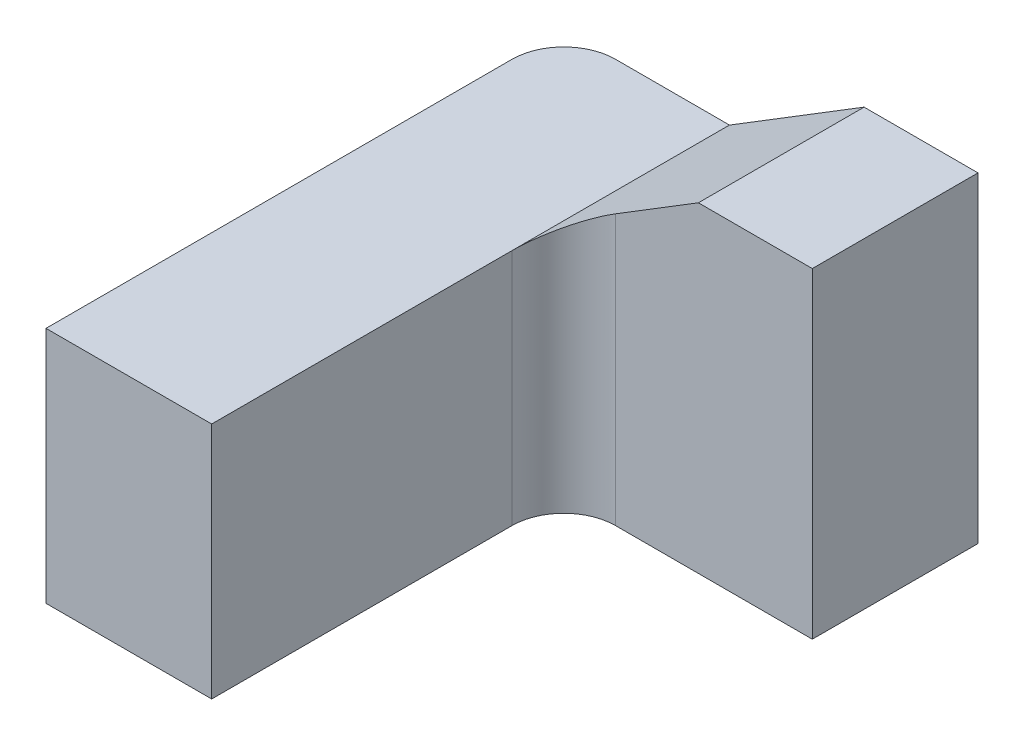
from build123d import *

# Parameters (mm, degrees)
EXTRUDE_1_DEPTH = 0.16
SKETCH_2_W      = 0.16
SKETCH_2_H      = 0.23
EXTRUDE_2_DEPTH = 0.34
FILLET_1_R      = 0.05


with BuildPart() as part:
    # 草图1 → 凸台-拉伸1 (new body)
    with BuildSketch(Plane.XY):
        Polygon((0, 0), (0, 0.23), (0.16, 0.23), (0.29, 0.31), (0.4, 0.31), (0.4, 0), align=None)
    extrude(amount=EXTRUDE_1_DEPTH)

    # 草图2 → 凸台-拉伸2 (add)
    with BuildSketch(Plane.XY.offset(0.16)):
        with Locations((0.08, 0.115)):
            Rectangle(SKETCH_2_W, SKETCH_2_H)
    extrude(amount=EXTRUDE_2_DEPTH)

    # 圆角1
    fillet_1_edges = [part.edges().sort_by_distance(p)[0] for p in [
        (0.16, 0.115, 0.16),
        (0, 0.115, 0),
    ]]
    fillet(fillet_1_edges, radius=FILLET_1_R)


solid = part.part
